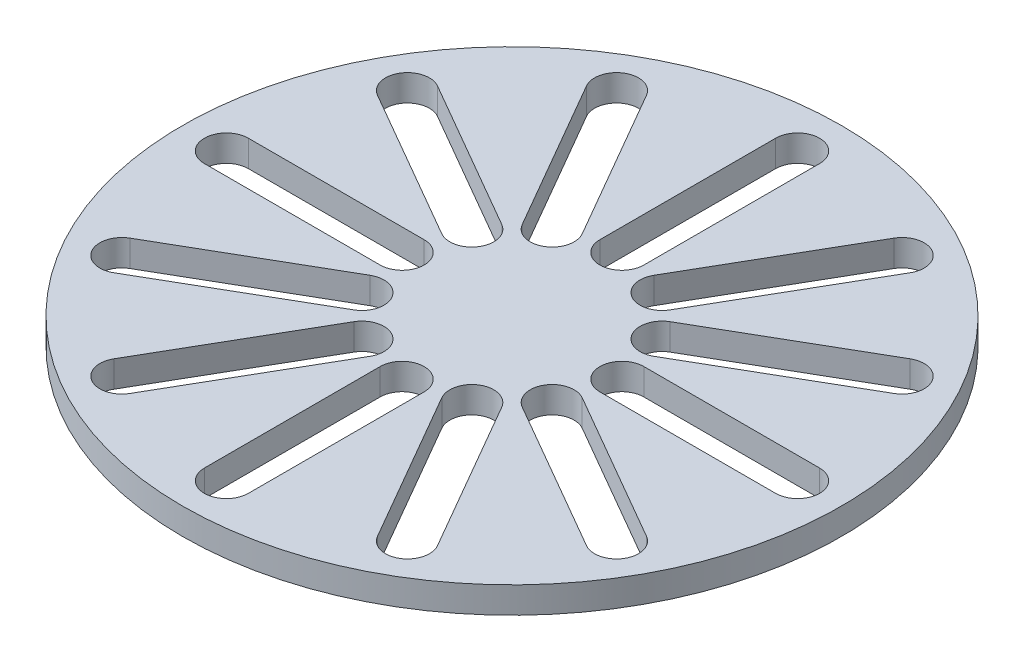
from build123d import *

# Parameters (mm, degrees)
SKETCH1_R           = 95.25
BOSS_EXTRUDE3_DEPTH = 7.62
SCALE1_SCALE        = 2


with BuildPart() as part:
    # Sketch1 → Boss-Extrude3 (new body)
    with BuildSketch(Plane(origin=(0, 0, 0), x_dir=(1, 0, 0), z_dir=(0, 1, 0))):
        Circle(SKETCH1_R)
        with BuildLine():
            Line((6.35, 82.55), (6.35, 31.75))
            ThreePointArc((6.35, 31.75), (0, 25.4), (-6.35, 31.75))
            Line((-6.35, 31.75), (-6.35, 82.55))
            ThreePointArc((-6.35, 82.55), (0, 88.9), (6.35, 82.55))
        make_face(mode=Mode.SUBTRACT)
        with BuildLine():
            Line((35.775738686, 74.665397082), (10.375738686, 30.67130657))
            ThreePointArc((10.375738686, 30.67130657), (12.7, 21.997045256), (21.374261314, 24.32130657))
            Line((21.374261314, 24.32130657), (46.774261314, 68.315397082))
            ThreePointArc((46.774261314, 68.315397082), (44.45, 76.989658396), (35.775738686, 74.665397082))
        make_face(mode=Mode.SUBTRACT)
        with BuildLine():
            Line((68.315397082, 46.774261314), (24.32130657, 21.374261314))
            ThreePointArc((24.32130657, 21.374261314), (21.997045256, 12.7), (30.67130657, 10.375738686))
            Line((30.67130657, 10.375738686), (74.665397082, 35.775738686))
            ThreePointArc((74.665397082, 35.775738686), (76.989658396, 44.45), (68.315397082, 46.774261314))
        make_face(mode=Mode.SUBTRACT)
        with BuildLine():
            Line((82.55, 6.35), (31.75, 6.35))
            ThreePointArc((31.75, 6.35), (25.4, 0), (31.75, -6.35))
            Line((31.75, -6.35), (82.55, -6.35))
            ThreePointArc((82.55, -6.35), (88.9, 0), (82.55, 6.35))
        make_face(mode=Mode.SUBTRACT)
        with BuildLine():
            Line((74.665397082, -35.775738686), (30.67130657, -10.375738686))
            ThreePointArc((30.67130657, -10.375738686), (21.997045256, -12.7), (24.32130657, -21.374261314))
            Line((24.32130657, -21.374261314), (68.315397082, -46.774261314))
            ThreePointArc((68.315397082, -46.774261314), (76.989658396, -44.45), (74.665397082, -35.775738686))
        make_face(mode=Mode.SUBTRACT)
        with BuildLine():
            Line((46.774261314, -68.315397082), (21.374261314, -24.32130657))
            ThreePointArc((21.374261314, -24.32130657), (12.7, -21.997045256), (10.375738686, -30.67130657))
            Line((10.375738686, -30.67130657), (35.775738686, -74.665397082))
            ThreePointArc((35.775738686, -74.665397082), (44.45, -76.989658396), (46.774261314, -68.315397082))
        make_face(mode=Mode.SUBTRACT)
        with BuildLine():
            Line((6.35, -82.55), (6.35, -31.75))
            ThreePointArc((6.35, -31.75), (0, -25.4), (-6.35, -31.75))
            Line((-6.35, -31.75), (-6.35, -82.55))
            ThreePointArc((-6.35, -82.55), (0, -88.9), (6.35, -82.55))
        make_face(mode=Mode.SUBTRACT)
        with BuildLine():
            Line((-35.775738686, -74.665397082), (-10.375738686, -30.67130657))
            ThreePointArc((-10.375738686, -30.67130657), (-12.7, -21.997045256), (-21.374261314, -24.32130657))
            Line((-21.374261314, -24.32130657), (-46.774261314, -68.315397082))
            ThreePointArc((-46.774261314, -68.315397082), (-44.45, -76.989658396), (-35.775738686, -74.665397082))
        make_face(mode=Mode.SUBTRACT)
        with BuildLine():
            Line((-68.315397082, -46.774261314), (-24.32130657, -21.374261314))
            ThreePointArc((-24.32130657, -21.374261314), (-21.997045256, -12.7), (-30.67130657, -10.375738686))
            Line((-30.67130657, -10.375738686), (-74.665397082, -35.775738686))
            ThreePointArc((-74.665397082, -35.775738686), (-76.989658396, -44.45), (-68.315397082, -46.774261314))
        make_face(mode=Mode.SUBTRACT)
        with BuildLine():
            Line((-82.55, -6.35), (-31.75, -6.35))
            ThreePointArc((-31.75, -6.35), (-25.4, 0), (-31.75, 6.35))
            Line((-31.75, 6.35), (-82.55, 6.35))
            ThreePointArc((-82.55, 6.35), (-88.9, 0), (-82.55, -6.35))
        make_face(mode=Mode.SUBTRACT)
        with BuildLine():
            Line((-74.665397082, 35.775738686), (-30.67130657, 10.375738686))
            ThreePointArc((-30.67130657, 10.375738686), (-21.997045256, 12.7), (-24.32130657, 21.374261314))
            Line((-24.32130657, 21.374261314), (-68.315397082, 46.774261314))
            ThreePointArc((-68.315397082, 46.774261314), (-76.989658396, 44.45), (-74.665397082, 35.775738686))
        make_face(mode=Mode.SUBTRACT)
        with BuildLine():
            Line((-46.774261314, 68.315397082), (-21.374261314, 24.32130657))
            ThreePointArc((-21.374261314, 24.32130657), (-12.7, 21.997045256), (-10.375738686, 30.67130657))
            Line((-10.375738686, 30.67130657), (-35.775738686, 74.665397082))
            ThreePointArc((-35.775738686, 74.665397082), (-44.45, 76.989658396), (-46.774261314, 68.315397082))
        make_face(mode=Mode.SUBTRACT)
    extrude(amount=BOSS_EXTRUDE3_DEPTH)


with BuildPart() as part_1:
    # Scale1: scaled about (0, 3.81, 0)
    add(part.part.scale(SCALE1_SCALE).moved(Location((0, -3.81, 0))))


solid = part_1.part
